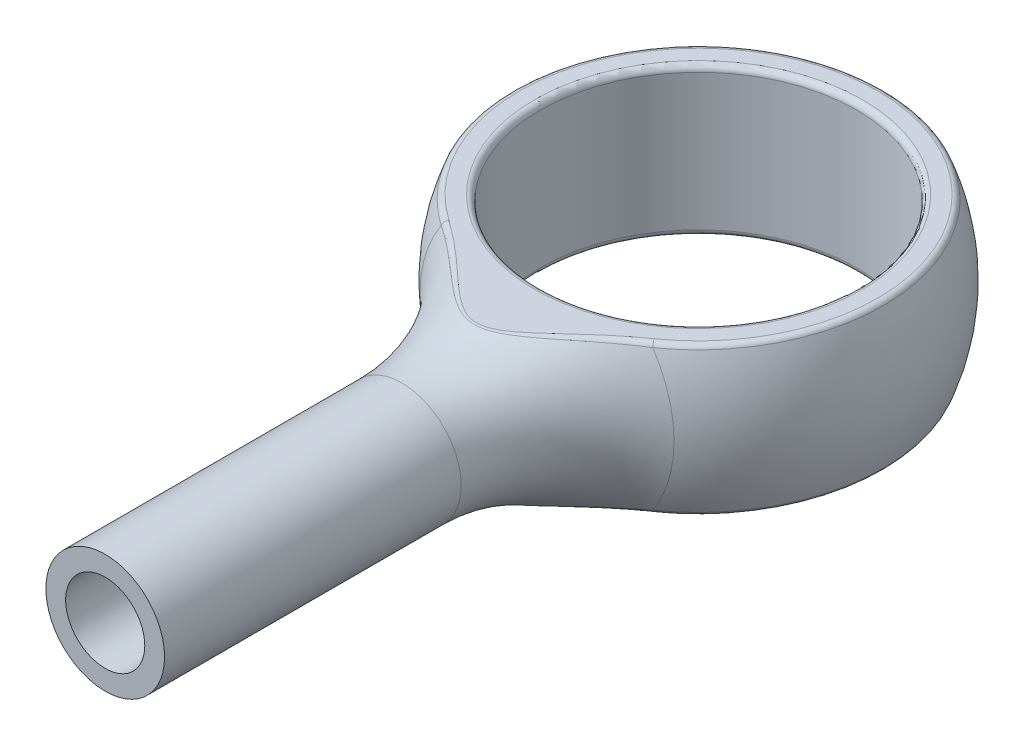
from build123d import *

# Parameters (mm, degrees)
CUT_EXTRUDE1_DEPTH      = 6
CUT_EXTRUDE1_DEPTH_BACK = 6
SKETCH5_R               = 4
CUT_EXTRUDE2_DEPTH      = 2.8750001
CUT_EXTRUDE2_DEPTH_BACK = 2.8750001
FILLET1_R               = 0.15
SKETCH6_R               = 1
CUT_EXTRUDE3_DEPTH      = 5


with BuildPart() as part:
    # Sketch2 → Revolve1 (revolve)
    with BuildSketch(Plane(origin=(0, 0, 0), x_dir=(1, 0, 0), z_dir=(0, 1, 0))):
        with BuildLine():
            Line((-1.5, -15), (-1.5, -7.5))
            ThreePointArc((-1.5, -7.5), (-1.948980687, -5.476190987), (-3.211678832, -3.832116788))
            ThreePointArc((-3.211678832, -3.832116788), (-4.698967117, 1.708715315), (0, 5))
            Line((0, 5), (0, -15))
            Line((0, -15), (-1.5, -15))
        make_face()
    revolve(axis=Axis((0, 0, 0), (0, 0, -1)))

    # Sketch4 → Cut-Extrude1 (cut, two sides)
    with BuildSketch(Plane(origin=(0, 0, 0), x_dir=(0, 0, -1), z_dir=(1, 0, 0))) as cut_extrude1_sk:
        with BuildLine():
            Line((8.781517746, 1.875), (-9.267406652, 1.875))
            ThreePointArc((-9.267406652, 1.875), (-10.77093565, 2.106415246), (-12.135288834, 2.779239779))
            Line((-12.135288834, 2.779239779), (-18.987551921, 7.577246046))
            Line((-18.987551921, 7.577246046), (8.781517746, 7.577246046))
            Line((8.781517746, 7.577246046), (8.781517746, 1.875))
        make_face()
        with BuildLine():
            Line((8.781517746, -7.577246046), (8.781517746, -1.875))
            Line((8.781517746, -1.875), (-9.267406652, -1.875))
            ThreePointArc((-9.267406652, -1.875), (-10.77093565, -2.106415246), (-12.135288834, -2.779239779))
            Line((-12.135288834, -2.779239779), (-18.987551921, -7.577246046))
            Line((-18.987551921, -7.577246046), (8.781517746, -7.577246046))
        make_face()
    extrude(amount=CUT_EXTRUDE1_DEPTH, mode=Mode.SUBTRACT)
    extrude(cut_extrude1_sk.sketch, amount=-CUT_EXTRUDE1_DEPTH_BACK, mode=Mode.SUBTRACT)

    # Sketch5 → Cut-Extrude2 (cut, two sides)
    with BuildSketch(Plane(origin=(0, 0, 0), x_dir=(1, 0, 0), z_dir=(0, 1, 0))) as cut_extrude2_sk:
        Circle(SKETCH5_R)
    extrude(amount=CUT_EXTRUDE2_DEPTH, mode=Mode.SUBTRACT)
    extrude(cut_extrude2_sk.sketch, amount=-CUT_EXTRUDE2_DEPTH_BACK, mode=Mode.SUBTRACT)

    # Fillet1
    fillet1_edges = [part.edges().sort_by_distance(p)[0] for p in [
        (0, -1.875, -4.635124054),
        (0, 1.875, -4.635124054),
        (-1e-09, 1.875, 5.642942998),
        (1e-09, -1.875, 5.642942998),
        (-4, -1.875, 0),
        (-4, 1.875, 0),
    ]]
    fillet(fillet1_edges, radius=FILLET1_R)

    # Sketch6 → Cut-Extrude3 (cut)
    with BuildSketch(Plane.XY.offset(15)):
        Circle(SKETCH6_R)
    extrude(amount=-CUT_EXTRUDE3_DEPTH, mode=Mode.SUBTRACT)


solid = part.part
